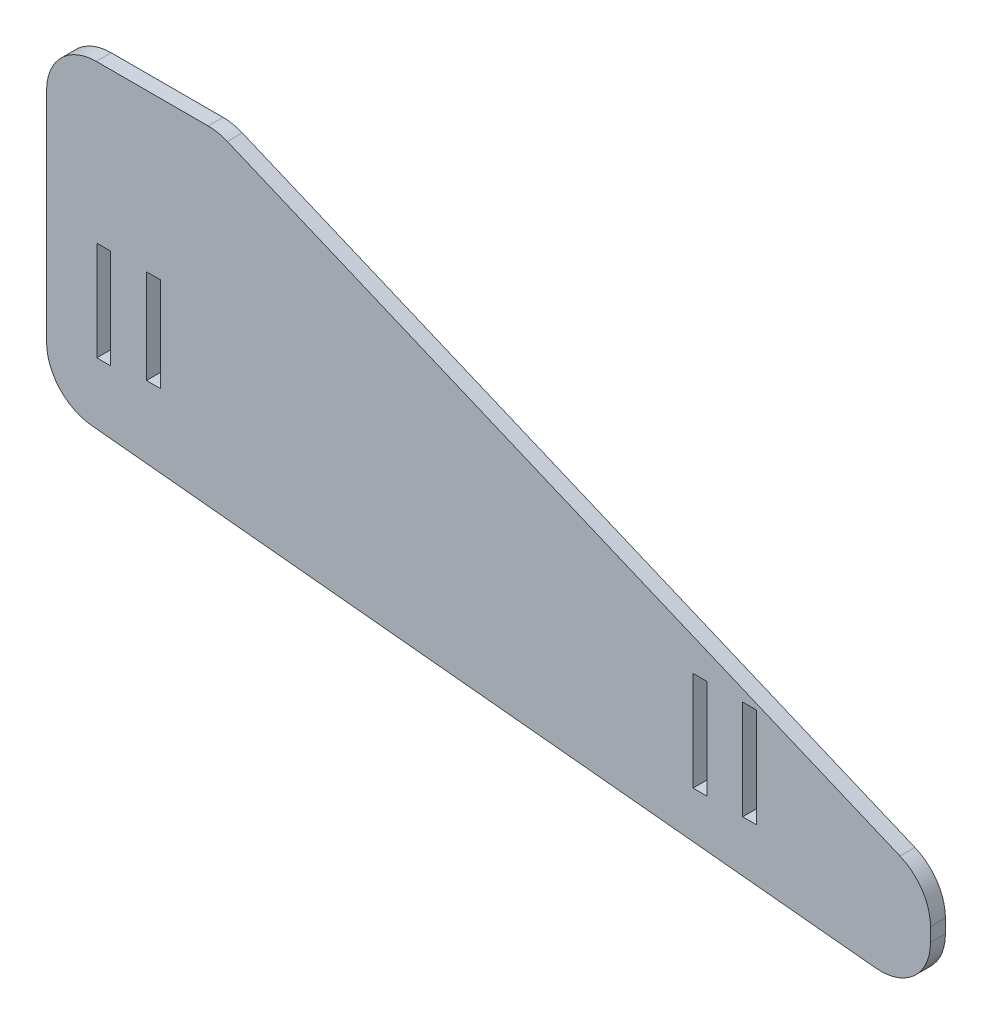
from build123d import *

# Parameters (mm, degrees)
SKETCH2_W           = 2.8
SKETCH2_H           = 20
SKETCH2_H_2         = 20.000000002
SKETCH2_H_3         = 18.952705736
BOSS_EXTRUDE1_DEPTH = 3
FILLET1_R           = 10
SKETCH3_W           = 34.524922621
SKETCH3_H           = 4
CUT_EXTRUDE1_DEPTH  = 10
FILLET2_R           = 10


with BuildPart() as part:
    # Sketch2 → Boss-Extrude1 (new body)
    with BuildSketch(Plane.XY):
        Polygon((-20, 103.817072851), (5, 103.817072851), (157.9, 39.606577468), (157.9, 19.126615409), (-20, 36.779238836), align=None)
        with Locations((111.5, 43.194495368)):
            Rectangle(SKETCH2_W, SKETCH2_H, mode=Mode.SUBTRACT)
        with Locations((121.5, 43.194495368)):
            Rectangle(SKETCH2_W, SKETCH2_H, mode=Mode.SUBTRACT)
        with Locations((-8.5, 58.194495367)):
            Rectangle(SKETCH2_W, SKETCH2_H_2, mode=Mode.SUBTRACT)
        with Locations((1.5, 58.7181425)):
            Rectangle(SKETCH2_W, SKETCH2_H_3, mode=Mode.SUBTRACT)
    extrude(amount=BOSS_EXTRUDE1_DEPTH)

    # Fillet1
    fillet1_edges = [part.edges().sort_by_distance(p)[0] for p in [
        (157.9, 39.606577468, 1.5),
        (157.9, 19.126615409, 1.5),
        (-20, 36.779238836, 1.5),
    ]]
    fillet(fillet1_edges, radius=FILLET1_R)

    # Sketch3 → Cut-Extrude1 (cut)
    with BuildSketch(Plane(origin=(0, 0, 0), x_dir=(-1, 0, 0), z_dir=(0, 0, -1))):
        with Locations((2.737538689, 101.817072851)):
            Rectangle(SKETCH3_W, SKETCH3_H)
    extrude(amount=-CUT_EXTRUDE1_DEPTH, mode=Mode.SUBTRACT)

    # Fillet2
    fillet2_edges = [part.edges().sort_by_distance(p)[0] for p in [
        (14.524922621, 99.817072851, 1.5),
        (-20, 99.817072851, 1.5),
    ]]
    fillet(fillet2_edges, radius=FILLET2_R)


solid = part.part
